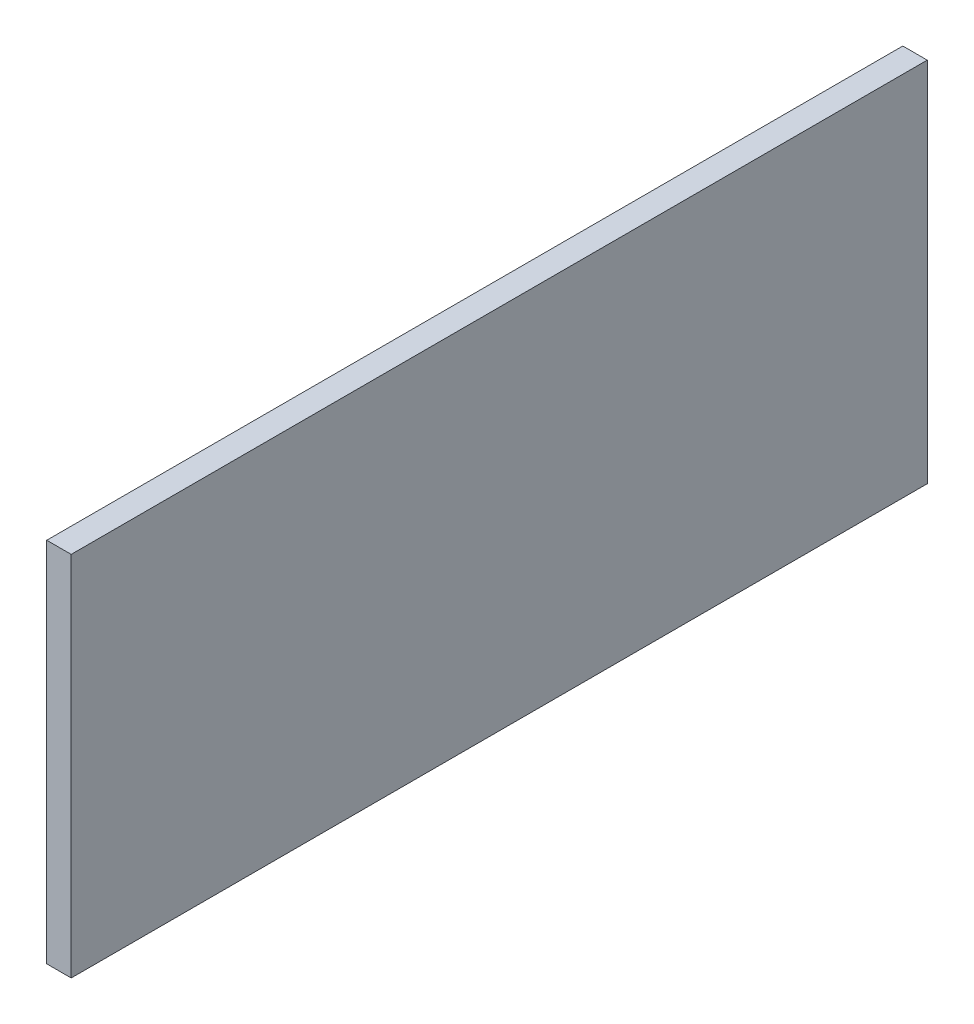
from build123d import *

# Parameters (mm, degrees)
SKETCH2_W           = 88.9
SKETCH2_H           = 38.1
BOSS_EXTRUDE1_DEPTH = 2.54


with BuildPart() as part:
    # Sketch2 → Boss-Extrude1 (new body)
    with BuildSketch(Plane(origin=(0, 0, 0), x_dir=(0, 0, -1), z_dir=(1, 0, 0))):
        Rectangle(SKETCH2_W, SKETCH2_H)
    extrude(amount=BOSS_EXTRUDE1_DEPTH)


solid = part.part
